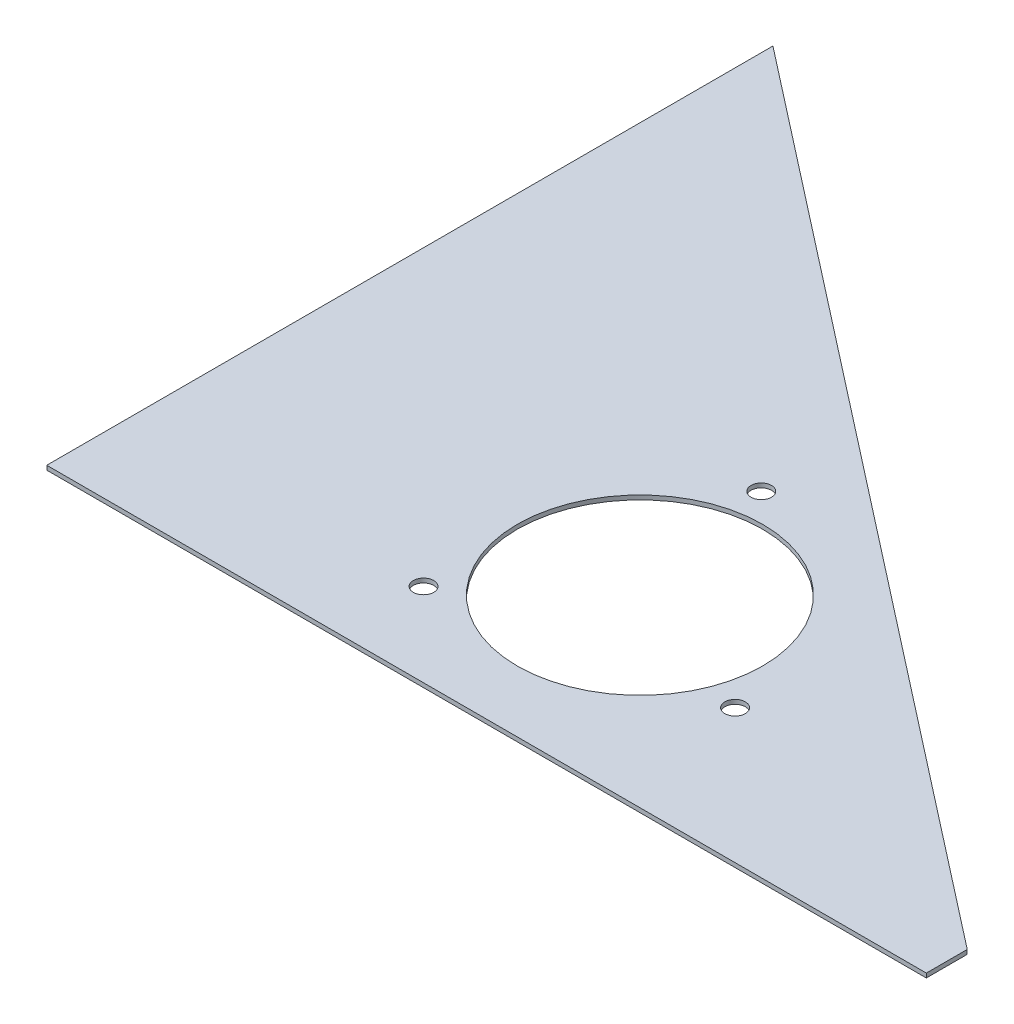
from build123d import *

# Parameters (mm, degrees)
BOSS_EXTRUDE1_DEPTH = 2.65684
SKETCH2_R           = 76.2
CUT_EXTRUDE1_DEPTH  = 3.65684
SKETCH3_R           = 6.35
CUT_EXTRUDE2_DEPTH  = 3.65684


with BuildPart() as part:
    # Sketch1 → Boss-Extrude1 (new body)
    with BuildSketch(Plane(origin=(0, 0, 0), x_dir=(1, 0, 0), z_dir=(0, 1, 0))):
        Polygon((0, 450.85), (0, 0), (546.1, 0), (546.1, 25.4), align=None)
    extrude(amount=BOSS_EXTRUDE1_DEPTH)

    # Sketch2 → Cut-Extrude1 (cut, through all)
    with BuildSketch(Plane.XZ):
        with Locations((254, -114.3)):
            Circle(SKETCH2_R)
    extrude(amount=-CUT_EXTRUDE1_DEPTH, mode=Mode.SUBTRACT)

    # Sketch3 → Cut-Extrude2 (cut, through all)
    with BuildSketch(Plane.XZ):
        with Locations((344.060644326, -83.289633288)):
            Circle(SKETCH3_R)
        with Locations((235.82544319, -207.799989223)):
            Circle(SKETCH3_R)
        with Locations((182.113912484, -51.810377489)):
            Circle(SKETCH3_R)
    extrude(amount=-CUT_EXTRUDE2_DEPTH, mode=Mode.SUBTRACT)


solid = part.part
